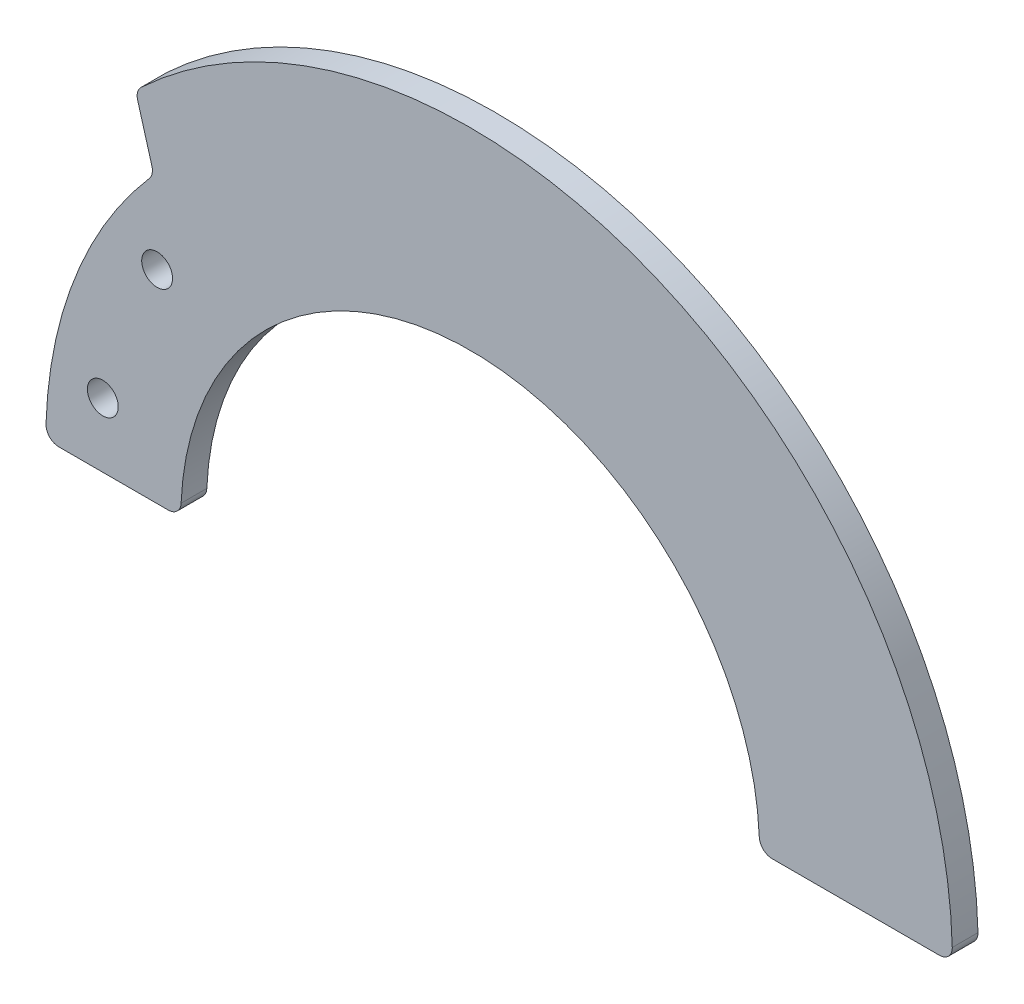
from build123d import *

# Parameters (mm, degrees)
BOSS_EXTRU_1_DEPTH      = 2
D_GAGEMENT_M21_D        = 2.4
D_GAGEMENT_M21_DEPTH    = 10
D_GAGEMENT_M21_TIP      = 0.721032743
ENL_V_MAT_EXTRU_1_REACH = 4
CONG_1_R                = 1


with BuildPart() as part:
    # Esquisse1 → Boss.-Extru.1 (new body)
    with BuildSketch(Plane.XY):
        with BuildLine():
            Line((-22.5, 0), (-37.5, 0))
            ThreePointArc((-37.5, 0), (0, 37.5), (37.5, 0))
            Line((37.5, 0), (22.5, 0))
            ThreePointArc((22.5, 0), (0, 22.5), (-22.5, 0))
        make_face()
    extrude(amount=BOSS_EXTRU_1_DEPTH)

    # Dégagement M21
    with Locations(Plane.XY.offset(2)):
        with Locations((-28.565713714, 5), (-24.343075181, 15.761176693)):
            Hole(D_GAGEMENT_M21_D / 2, depth=D_GAGEMENT_M21_DEPTH)
            with Locations((0, 0, -(D_GAGEMENT_M21_DEPTH + D_GAGEMENT_M21_TIP / 2))):  # 118° drill point
                Cone(0, D_GAGEMENT_M21_D / 2, D_GAGEMENT_M21_TIP, mode=Mode.SUBTRACT)

    # Esquisse7 → Enlèv. mat.-Extru.1 (cut, up to next)
    with BuildSketch(Plane.XY.offset(2), mode=Mode.PRIVATE) as enl_v_mat_extru_1_sk1:
        with BuildLine():
            Line((-24.596747752, 22), (-26.024027359, 27))
            ThreePointArc((-26.024027359, 27), (-34.511961883, 14.66882705), (-37.5, 0))
            Line((-37.5, 0), (-33, 0))
            ThreePointArc((-33, 0), (-30.827687846, 11.775128963), (-24.596747752, 22))
        make_face()
    enl_v_mat_extru_1_tool1 = extrude(enl_v_mat_extru_1_sk1.sketch, amount=-ENL_V_MAT_EXTRU_1_REACH, mode=Mode.PRIVATE) & part.part
    add(enl_v_mat_extru_1_tool1.solids().sort_by_distance((-31.93558, 12.954639, 2))[0], mode=Mode.SUBTRACT)

    # Congé1
    cong_1_edges = [part.edges().sort_by_distance(p)[0] for p in [
        (-24.596747752, 22, 1),
        (-33, 0, 1),
        (-26.024027359, 27, 1),
        (-22.5, 0, 1),
        (37.5, 0, 1),
        (22.5, 0, 1),
    ]]
    fillet(cong_1_edges, radius=CONG_1_R)


solid = part.part
